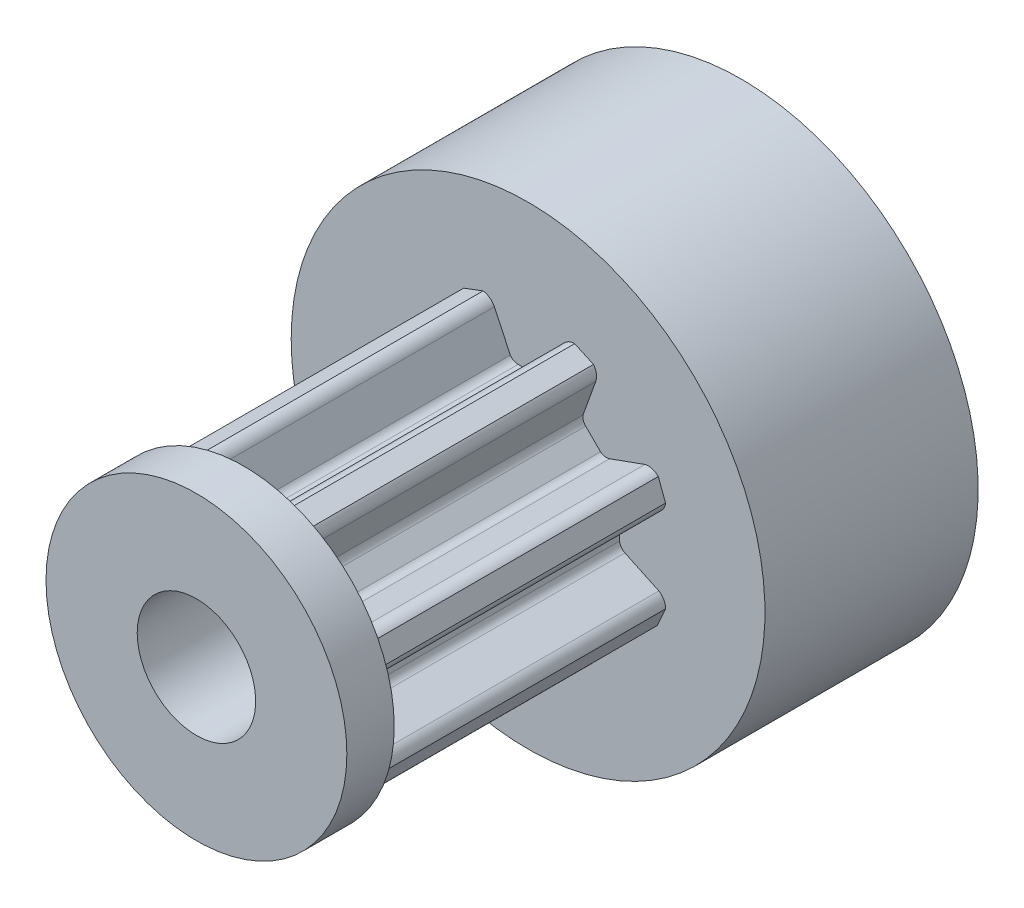
from build123d import *

# Parameters (mm, degrees)
SKETCH1_W                    = 6.35
SKETCH1_H                    = 2
BOSS_EXTRUDE1_DEPTH          = 12
SKETCH3_R                    = 10
BOSS_EXTRUDE2_DEPTH          = 9
F_5_0_5_DIAMETER_HOLE1_D     = 5
F_5_0_5_DIAMETER_HOLE1_DEPTH = 23


with BuildPart() as part:
    # Sketch1 → Revolve1 (revolve)
    with BuildSketch(Plane(origin=(0, 0, 0), x_dir=(1, 0, 0), z_dir=(0, 1, 0))):
        with Locations((3.175, -13)):
            Rectangle(SKETCH1_W, SKETCH1_H)
    revolve(axis=Axis((0, 0, 12), (0, 0, 1)))

    # Sketch2 → Boss-Extrude1 (add)
    with BuildSketch(Plane(origin=(0, 0, 12), x_dir=(-1, 0, 0), z_dir=(0, 0, -1))):
        with BuildLine():
            Line((-2.875186934, -4.932808292), (-2.337585335, -3.444483277))
            ThreePointArc((-2.337585335, -3.444483277), (-2.320135009, -3.243617805), (-2.400419134, -3.058669404))
            Line((-2.400419134, -3.058669404), (-3.024832437, -2.4306198))
            ThreePointArc((-3.024832437, -2.4306198), (-3.188663853, -2.33311555), (-3.378852537, -2.3198462))
            Line((-3.378852537, -2.3198462), (-4.867663341, -2.855580601))
            ThreePointArc((-4.867663341, -2.855580601), (-5.169157529, -2.882959187), (-5.446384241, -2.761329901))
            Line((-5.446384241, -2.761329901), (-5.807587241, -1.966542116))
            ThreePointArc((-5.807587241, -1.966542116), (-5.731084845, -1.673369369), (-5.521086391, -1.454958001))
            Line((-5.521086391, -1.454958001), (-4.088539945, -0.782695026))
            ThreePointArc((-4.088539945, -0.782695026), (-3.934167363, -0.653000933), (-3.860158544, -0.465453215))
            Line((-3.860158544, -0.465453215), (-3.857587291, 0.420171804))
            ThreePointArc((-3.857587291, 0.420171804), (-3.904487679, 0.604964025), (-4.029588541, 0.748830581))
            Line((-4.029588541, 0.748830581), (-5.461158184, 1.422757368))
            ThreePointArc((-5.461158184, 1.422757368), (-5.693706352, 1.61658637), (-5.803730347, 1.89862015))
            Line((-5.803730347, 1.89862015), (-5.497139595, 2.716029083))
            ThreePointArc((-5.497139595, 2.716029083), (-5.235739777, 2.86923814), (-4.93280828, 2.875186941))
            Line((-4.93280828, 2.875186941), (-3.444483265, 2.337585342))
            ThreePointArc((-3.444483265, 2.337585342), (-3.243617793, 2.320135016), (-3.058669391, 2.40041914))
            Line((-3.058669391, 2.40041914), (-2.430619781, 3.024832451))
            ThreePointArc((-2.430619781, 3.024832451), (-2.333115531, 3.188663866), (-2.319846181, 3.378852551))
            Line((-2.319846181, 3.378852551), (-2.855580582, 4.867663354))
            ThreePointArc((-2.855580582, 4.867663354), (-2.882959167, 5.169157543), (-2.761329882, 5.446384254))
            Line((-2.761329882, 5.446384254), (-1.966542082, 5.807587254))
            ThreePointArc((-1.966542082, 5.807587254), (-1.673369335, 5.731084833), (-1.454957982, 5.521086354))
            Line((-1.454957982, 5.521086354), (-0.782695007, 4.088539908))
            ThreePointArc((-0.782695007, 4.088539908), (-0.653000914, 3.934167326), (-0.465453196, 3.860158506))
            Line((-0.465453196, 3.860158506), (0.420171836, 3.857587254))
            ThreePointArc((0.420171836, 3.857587254), (0.604964057, 3.904487642), (0.748830613, 4.029588503))
            Line((0.748830613, 4.029588503), (1.4227574, 5.461158146))
            ThreePointArc((1.4227574, 5.461158146), (1.616586402, 5.693706315), (1.898620182, 5.80373031))
            Line((1.898620182, 5.80373031), (2.716029116, 5.497139558))
            ThreePointArc((2.716029116, 5.497139558), (2.869238173, 5.235739739), (2.875186973, 4.932808242))
            Line((2.875186973, 4.932808242), (2.337585375, 3.444483227))
            ThreePointArc((2.337585375, 3.444483227), (2.320135048, 3.243617755), (2.400419173, 3.058669354))
            Line((2.400419173, 3.058669354), (3.024832497, 2.43061973))
            ThreePointArc((3.024832497, 2.43061973), (3.188663912, 2.33311548), (3.378852597, 2.31984613))
            Line((3.378852597, 2.31984613), (4.8676634, 2.855580531))
            ThreePointArc((4.8676634, 2.855580531), (5.169157589, 2.882959117), (5.4463843, 2.761329831))
            Line((5.4463843, 2.761329831), (5.8075873, 1.966542031))
            ThreePointArc((5.8075873, 1.966542031), (5.731084879, 1.673369284), (5.5210864, 1.454957931))
            Line((5.5210864, 1.454957931), (4.088539954, 0.782694956))
            ThreePointArc((4.088539954, 0.782694956), (3.934167372, 0.653000863), (3.860158552, 0.465453145))
            Line((3.860158552, 0.465453145), (3.8575873, -0.420171864))
            ThreePointArc((3.8575873, -0.420171864), (3.904487688, -0.604964085), (4.029588549, -0.748830641))
            Line((4.029588549, -0.748830641), (5.461158192, -1.422757428))
            ThreePointArc((5.461158192, -1.422757428), (5.693706361, -1.616586429), (5.803730356, -1.898620209))
            Line((5.803730356, -1.898620209), (5.497139604, -2.716029143))
            ThreePointArc((5.497139604, -2.716029143), (5.235739785, -2.8692382), (4.932808288, -2.875187))
            Line((4.932808288, -2.875187), (3.444483273, -2.337585402))
            ThreePointArc((3.444483273, -2.337585402), (3.243617801, -2.320135075), (3.0586694, -2.4004192))
            Line((3.0586694, -2.4004192), (2.4306198, -3.0248325))
            ThreePointArc((2.4306198, -3.0248325), (2.33311555, -3.188663916), (2.3198462, -3.3788526))
            Line((2.3198462, -3.3788526), (2.855580601, -4.867663404))
            ThreePointArc((2.855580601, -4.867663404), (2.882959186, -5.169157592), (2.761329901, -5.446384304))
            Line((2.761329901, -5.446384304), (1.966542101, -5.807587304))
            ThreePointArc((1.966542101, -5.807587304), (1.673369354, -5.731084882), (1.454958001, -5.521086404))
            Line((1.454958001, -5.521086404), (0.782695026, -4.088539957))
            ThreePointArc((0.782695026, -4.088539957), (0.653000933, -3.934167376), (0.465453215, -3.860158556))
            Line((0.465453215, -3.860158556), (-0.420171797, -3.857587303))
            ThreePointArc((-0.420171797, -3.857587303), (-0.604964018, -3.904487692), (-0.748830574, -4.029588553))
            Line((-0.748830574, -4.029588553), (-1.422757361, -5.461158196))
            ThreePointArc((-1.422757361, -5.461158196), (-1.616586363, -5.693706365), (-1.898620143, -5.80373036))
            Line((-1.898620143, -5.80373036), (-2.716029077, -5.497139607))
            ThreePointArc((-2.716029077, -5.497139607), (-2.869238134, -5.235739789), (-2.875186934, -4.932808292))
        make_face()
    extrude(amount=BOSS_EXTRUDE1_DEPTH)

    # Sketch3 → Boss-Extrude2 (add)
    with BuildSketch(Plane.XY):
        Circle(SKETCH3_R)
    extrude(amount=-BOSS_EXTRUDE2_DEPTH)

    # Ø5.0 (5) Diameter Hole1
    with Locations(Plane(origin=(0, 0, -9), x_dir=(-1, 0, 0), z_dir=(0, 0, -1))):
        with Locations((0, 0)):
            Hole(F_5_0_5_DIAMETER_HOLE1_D / 2, depth=F_5_0_5_DIAMETER_HOLE1_DEPTH)


solid = part.part
